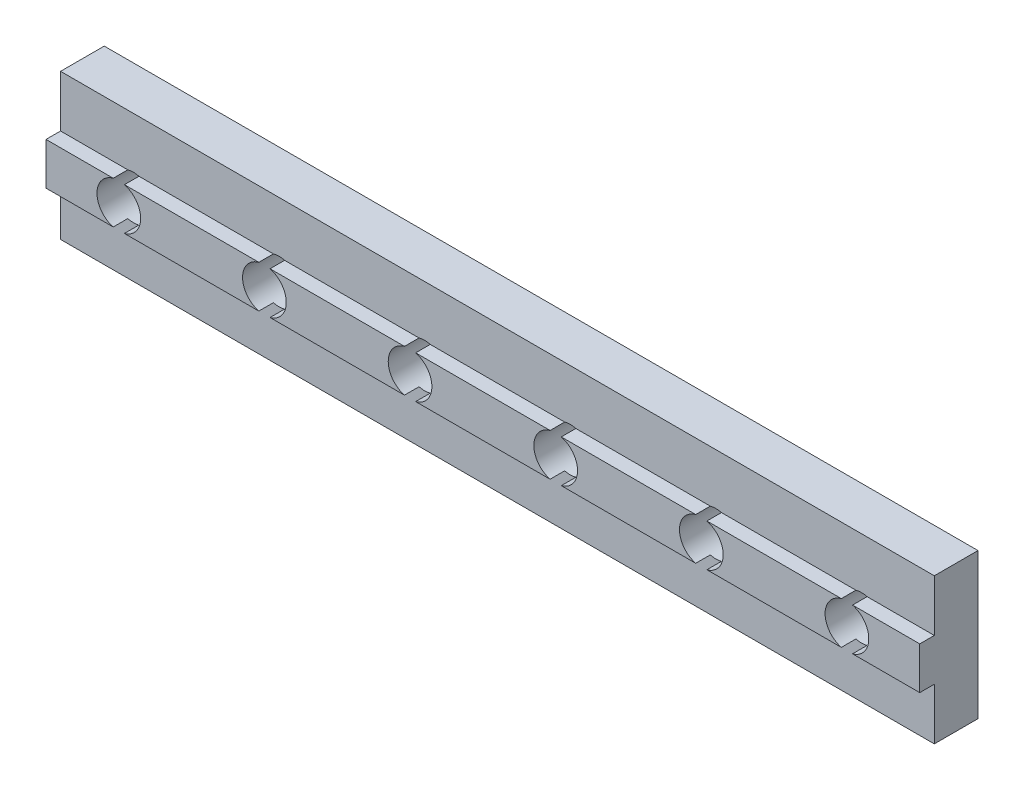
from build123d import *

# Parameters (mm, degrees)
ESQUISSE1_W                = 60
ESQUISSE1_H                = 10
BOSS_EXTRU_1_DEPTH         = 3
ESQUISSE2_W                = 60
ESQUISSE2_H                = 2.9
BOSS_EXTRU_2_DEPTH         = 1
ESQUISSE3_R                = 1.5
ENL_V_MAT_EXTRU_1_DEPTH    = 5
R_P_TITION_LIN_AIRE1_COUNT = 6
R_P_TITION_LIN_AIRE1_PITCH = 10


with BuildPart() as part:
    # Esquisse1 → Boss.-Extru.1 (new body)
    with BuildSketch(Plane.XY):
        with Locations((30, 5)):
            Rectangle(ESQUISSE1_W, ESQUISSE1_H)
    extrude(amount=BOSS_EXTRU_1_DEPTH)

    # Esquisse2 → Boss.-Extru.2 (add)
    with BuildSketch(Plane.XY.offset(3)):
        with Locations((30, 5)):
            Rectangle(ESQUISSE2_W, ESQUISSE2_H)
    extrude(amount=BOSS_EXTRU_2_DEPTH)

    # Esquisse3 → Enlèv. mat.-Extru.1 (cut, through all)
    with BuildSketch(Plane(origin=(0, 0, 0), x_dir=(-1, 0, 0), z_dir=(0, 0, -1))):
        with Locations((-55, 5)):
            Circle(ESQUISSE3_R)
    enl_v_mat_extru_1 = extrude(amount=-ENL_V_MAT_EXTRU_1_DEPTH, mode=Mode.SUBTRACT)

    # Répétition linéaire1: Enlèv. mat.-Extru.1 ×6
    with Locations(*[(-i * R_P_TITION_LIN_AIRE1_PITCH, 0, 0) for i in range(1, R_P_TITION_LIN_AIRE1_COUNT)]):
        add(enl_v_mat_extru_1, mode=Mode.SUBTRACT)


solid = part.part
